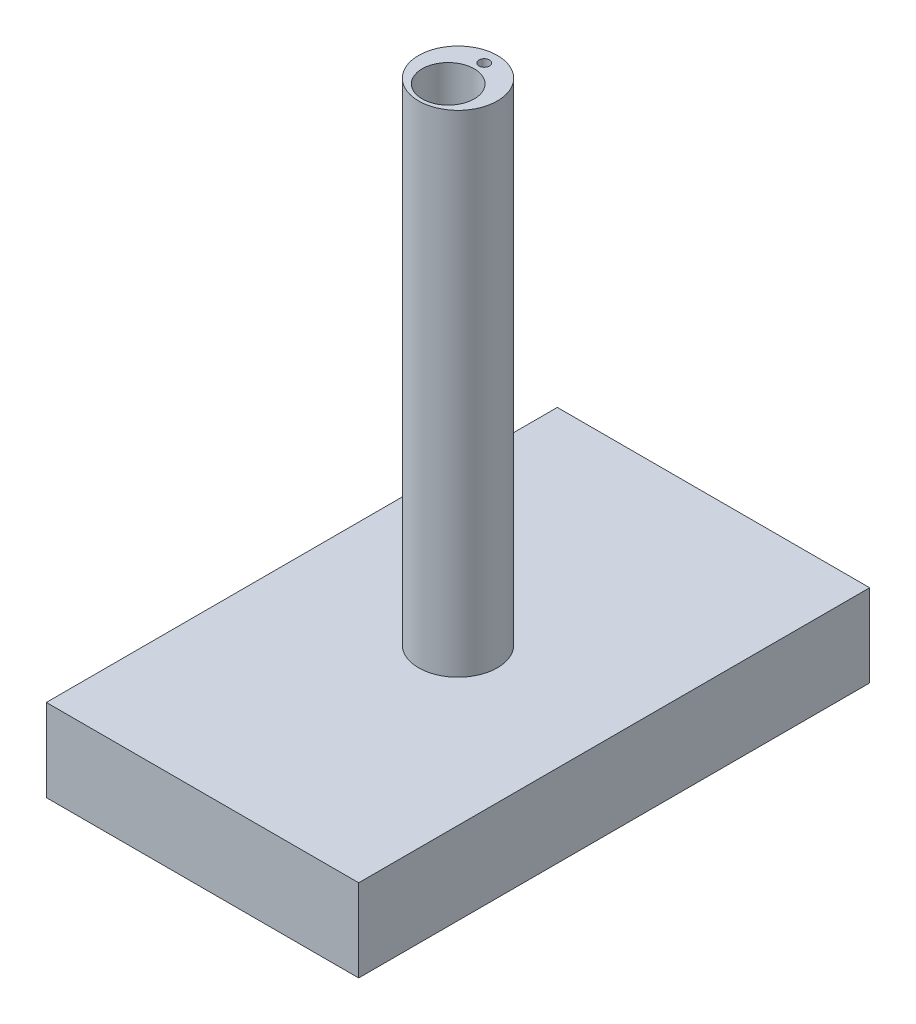
from build123d import *

# Parameters (mm, degrees)
SKETCH1_R           = 28.1
BOSS_EXTRUDE1_DEPTH = 350
SKETCH2_R           = 18.6
CUT_EXTRUDE1_DEPTH  = 58.8
SKETCH3_W           = 222.683092022
SKETCH3_H           = 364.2827524
BOSS_EXTRUDE2_DEPTH = 58.8
SKETCH4_W           = 207.917403516
SKETCH4_H           = 348.54429772
CUT_EXTRUDE2_DEPTH  = 48.8
SKETCH5_R           = 16.1
CUT_EXTRUDE3_DEPTH  = 350
SKETCH6_R           = 3.75
CUT_EXTRUDE5_DEPTH  = 400


with BuildPart() as part:
    # Sketch1 → Boss-Extrude1 (new body)
    with BuildSketch(Plane(origin=(0, 0, 0), x_dir=(1, 0, 0), z_dir=(0, 1, 0))):
        Circle(SKETCH1_R)
    extrude(amount=BOSS_EXTRUDE1_DEPTH)

    # Sketch2 → Cut-Extrude1 (cut)
    with BuildSketch(Plane(origin=(0, 350, 0), x_dir=(1, 0, 0), z_dir=(0, 1, 0))):
        with Locations((0, -7)):
            Circle(SKETCH2_R)
    extrude(amount=-CUT_EXTRUDE1_DEPTH, mode=Mode.SUBTRACT)

    # Sketch3 → Boss-Extrude2 (add)
    with BuildSketch(Plane(origin=(0, 0, 0), x_dir=(-1, 0, 0), z_dir=(0, -1, 0))):
        Rectangle(SKETCH3_W, SKETCH3_H)
    extrude(amount=BOSS_EXTRUDE2_DEPTH)

    # Sketch4 → Cut-Extrude2 (cut)
    with BuildSketch(Plane(origin=(0, -58.8, 0), x_dir=(-1, 0, 0), z_dir=(0, -1, 0))):
        Rectangle(SKETCH4_W, SKETCH4_H)
    extrude(amount=-CUT_EXTRUDE2_DEPTH, mode=Mode.SUBTRACT)

    # Sketch5 → Cut-Extrude3 (cut)
    with BuildSketch(Plane(origin=(0, 291.2, 0), x_dir=(1, 0, 0), z_dir=(0, 1, 0))):
        with Locations((0, -7)):
            Circle(SKETCH5_R)
    extrude(amount=-CUT_EXTRUDE3_DEPTH, mode=Mode.SUBTRACT)

    # Sketch6 → Cut-Extrude5 (cut)
    with BuildSketch(Plane(origin=(0, 350, 0), x_dir=(1, 0, 0), z_dir=(0, 1, 0))):
        with Locations((0, 18.75)):
            Circle(SKETCH6_R)
    extrude(amount=-CUT_EXTRUDE5_DEPTH, mode=Mode.SUBTRACT)


solid = part.part
